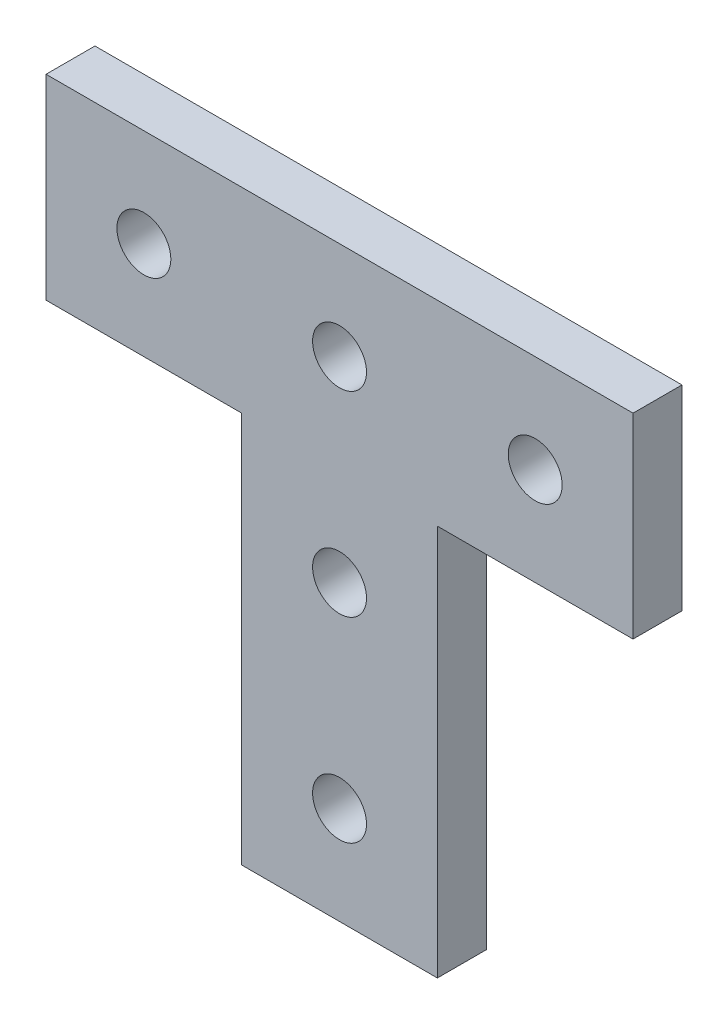
from build123d import *

# Parameters (mm, degrees)
BOSS_EXTRUDE1_DEPTH = 6.35
SKETCH2_R           = 3.5
CUT_EXTRUDE1_DEPTH  = 7.35


with BuildPart() as part:
    # Sketch1 → Boss-Extrude1 (new body)
    with BuildSketch(Plane.XY):
        Polygon((12.7, 0), (-12.7, 0), (-12.7, 50.8), (-38.1, 50.8), (-38.1, 76.2), (38.1, 76.2), (38.1, 50.8), (12.7, 50.8), align=None)
    extrude(amount=BOSS_EXTRUDE1_DEPTH)

    # Sketch2 → Cut-Extrude1 (cut, through all)
    with BuildSketch(Plane.XY.offset(6.35)):
        with Locations((0, 63.5)):
            Circle(SKETCH2_R)
        with Locations((25.4, 63.5)):
            Circle(SKETCH2_R)
        with Locations((-25.4, 63.5)):
            Circle(SKETCH2_R)
        with Locations((0, 38.1)):
            Circle(SKETCH2_R)
        with Locations((0, 12.7)):
            Circle(SKETCH2_R)
    extrude(amount=-CUT_EXTRUDE1_DEPTH, mode=Mode.SUBTRACT)


solid = part.part
